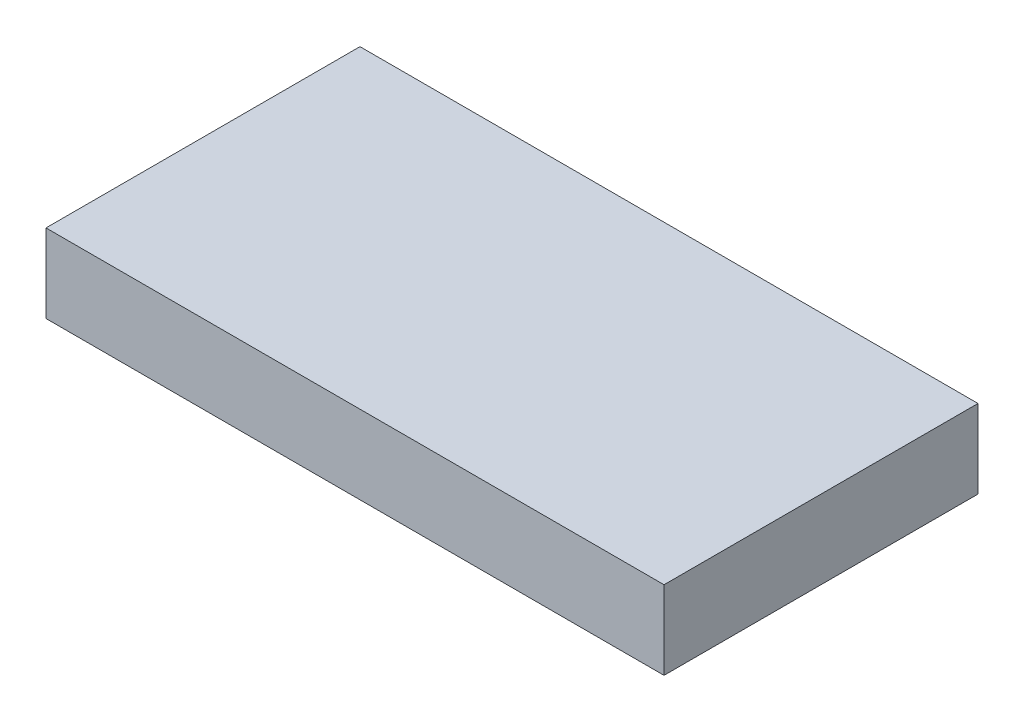
from build123d import *

# Parameters (mm, degrees)
SKETCH1_W           = 200
SKETCH1_H           = 101.6
BOSS_EXTRUDE1_DEPTH = 25.4


with BuildPart() as part:
    # Sketch1 → Boss-Extrude1 (new body)
    with BuildSketch(Plane(origin=(0, 0, 0), x_dir=(1, 0, 0), z_dir=(0, 1, 0))):
        with Locations((100, 50.8)):
            Rectangle(SKETCH1_W, SKETCH1_H)
    extrude(amount=BOSS_EXTRUDE1_DEPTH)


solid = part.part
